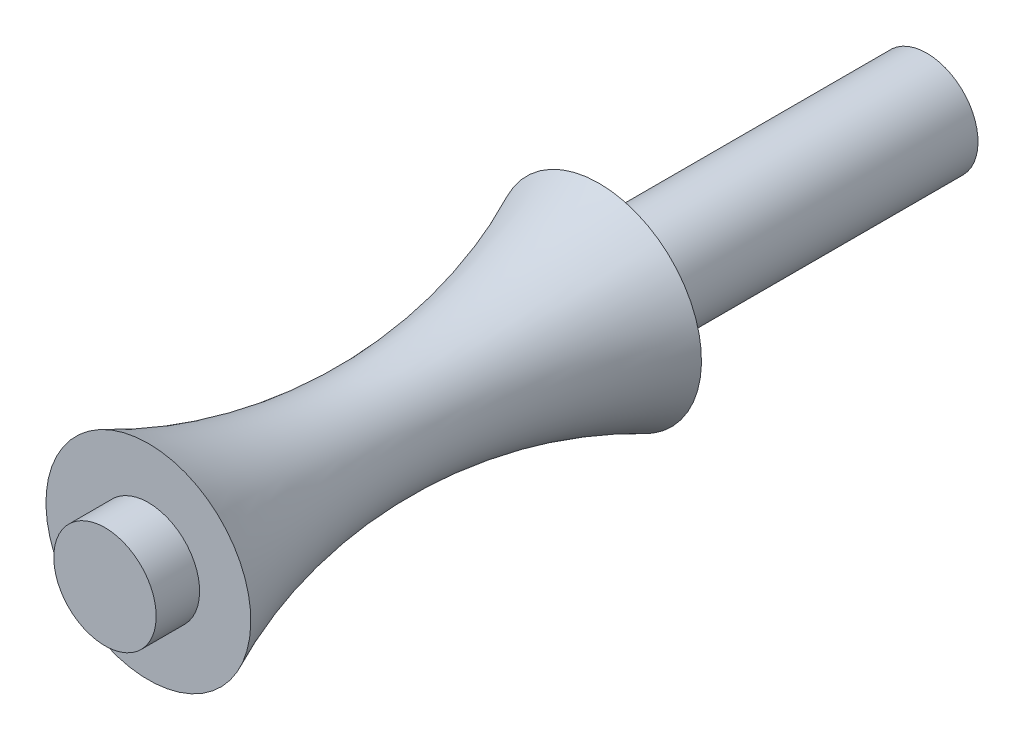
from build123d import *


with BuildPart() as part:
    # Szkic1 → Obrót1 (revolve)
    with BuildSketch(Plane(origin=(0, 0, 0), x_dir=(0, 0, -1), z_dir=(1, 0, 0))):
        with BuildLine():
            Line((24.687298198, -1.748229667), (-13.312701802, -1.748229667))
            Line((-13.312701802, -1.748229667), (-15.431171619, -1.748229667))
            Line((-15.431171619, -1.748229667), (-15.431171619, 0.751770333))
            Line((-15.431171619, 0.751770333), (-13.312701802, 0.751770333))
            Line((-13.312701802, 0.751770333), (-13.312701802, 3.251770333))
            ThreePointArc((-13.312701802, 3.251770333), (-2.312701802, 0.814239523), (8.687298198, 3.251770333))
            Line((8.687298198, 3.251770333), (8.687298198, 0.751770333))
            Line((8.687298198, 0.751770333), (24.687298198, 0.751770333))
            Line((24.687298198, 0.751770333), (24.687298198, -1.748229667))
        make_face()
    revolve(axis=Axis((0, -1.748229667, -24.687298198), (0, 0, 1)))


solid = part.part
